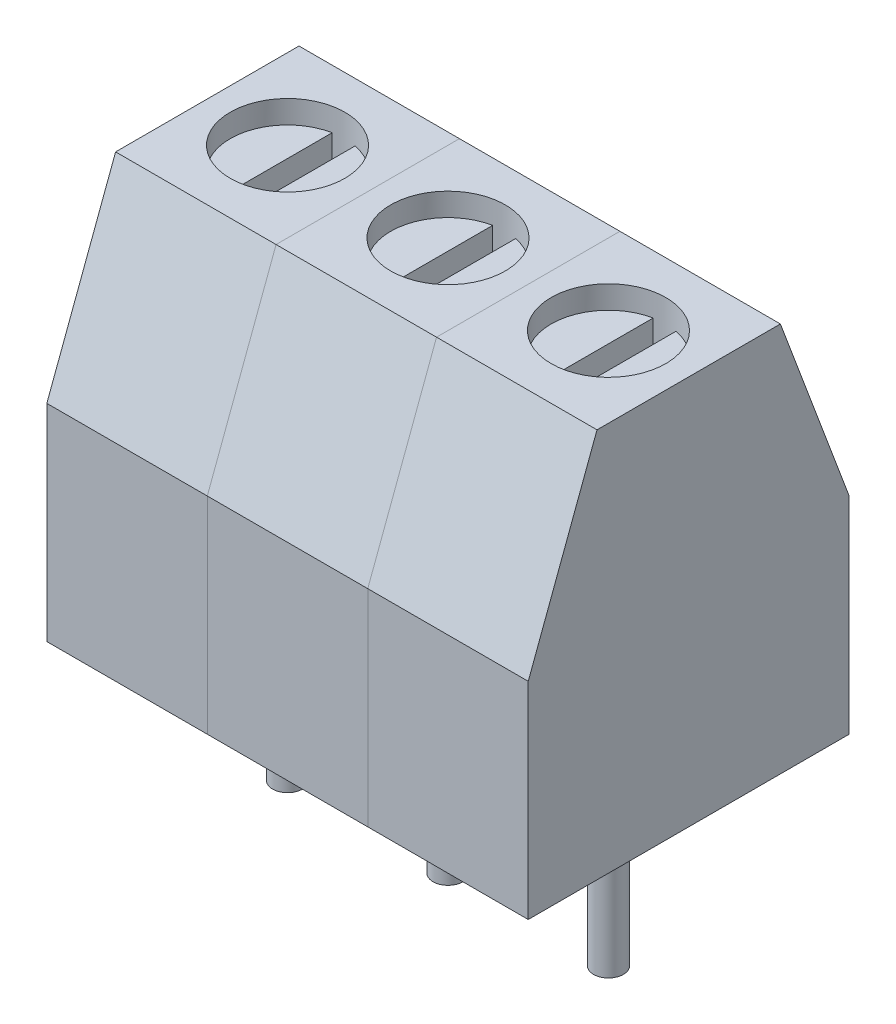
from build123d import *

# Parameters (mm, degrees)
EXTRUDE_1_DEPTH     = 3.5
SKETCH_3_W          = 3
SKETCH_3_H          = 4
CUT_EXTRUDE_1_DEPTH = 1.5
SKETCH_4_R          = 1.25
CUT_EXTRUDE_2_DEPTH = 0.5
CUT_EXTRUDE_3_DEPTH = 0.5
SKETCH_7_R          = 1
CUT_EXTRUDE_4_DEPTH = 3
SKETCH1_R           = 0.325
BOSS_EXTRUDE1_DEPTH = 3.5
LPATTERN1_COUNT     = 3
LPATTERN1_PITCH     = 3.5


with BuildPart() as part:
    # 스케치1 → 보스-돌출1 (new body)
    with BuildSketch(Plane(origin=(0, 0, 0), x_dir=(0, 0, -1), z_dir=(1, 0, 0))):
        Polygon((0, 0), (7, 0), (7, 4.5), (5.5, 8.5), (1.5, 8.5), (0, 4.5), align=None)
    extrude(amount=EXTRUDE_1_DEPTH)

    # 스케치3 → 컷-돌출1 (cut)
    with BuildSketch(Plane(origin=(0, 0, -7), x_dir=(-1, 0, 0), z_dir=(0, 0, -1))):
        with Locations((-1.75, 2.5)):
            Rectangle(SKETCH_3_W, SKETCH_3_H)
    extrude(amount=-CUT_EXTRUDE_1_DEPTH, mode=Mode.SUBTRACT)

    # 스케치4 → 컷-돌출2 (cut)
    with BuildSketch(Plane(origin=(0, 8.5, 0), x_dir=(1, 0, 0), z_dir=(0, 1, 0))):
        with Locations((1.75, 3.5)):
            Circle(SKETCH_4_R)
    extrude(amount=-CUT_EXTRUDE_2_DEPTH, mode=Mode.SUBTRACT)

    # 스케치5 → 컷-돌출3 (cut)
    with BuildSketch(Plane(origin=(0, 8, 0), x_dir=(1, 0, 0), z_dir=(0, 1, 0))):
        with BuildLine():
            Line((1.500050042, 4.724755085), (1.500050042, 2.275244915))
            ThreePointArc((1.500050042, 2.275244915), (1.75, 2.25), (1.999949958, 2.275244915))
            Line((1.999949958, 2.275244915), (1.999949958, 4.724755085))
            ThreePointArc((1.999949958, 4.724755085), (1.75, 4.75), (1.500050042, 4.724755085))
        make_face()
    extrude(amount=-CUT_EXTRUDE_3_DEPTH, mode=Mode.SUBTRACT)

    # 스케치7 → 컷-돌출4 (cut)
    with BuildSketch(Plane(origin=(0, 0, -5.5), x_dir=(-1, 0, 0), z_dir=(0, 0, -1))):
        with Locations((-1.75, 2)):
            Circle(SKETCH_7_R)
    extrude(amount=-CUT_EXTRUDE_4_DEPTH, mode=Mode.SUBTRACT)

    # Sketch1 → Boss-Extrude1 (add)
    with BuildSketch(Plane.XZ):
        with Locations((1.75, -3.5)):
            Circle(SKETCH1_R)
    extrude(amount=BOSS_EXTRUDE1_DEPTH)


with BuildPart() as lpattern1_1:
    # LPattern1: pattern copy
    add(part.part.moved(Location(Vector(1, 0, 0) * (1 * LPATTERN1_PITCH))))


with BuildPart() as lpattern1_2:
    # LPattern1: pattern copy
    add(part.part.moved(Location(Vector(1, 0, 0) * (2 * LPATTERN1_PITCH))))


solid = Compound([part.part, lpattern1_1.part, lpattern1_2.part])
